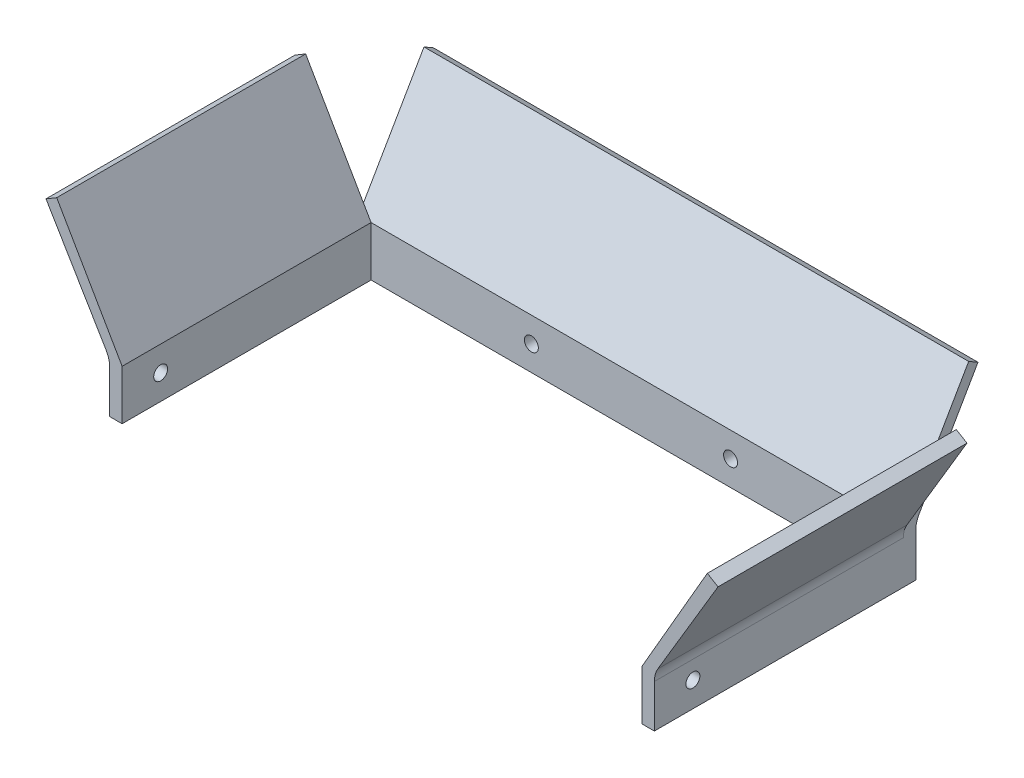
from build123d import *

# Parameters (mm, degrees)
SKETCH1_W           = 138.92560988
SKETCH1_H           = 12.7
SKETCH1_R           = 1.778
BOSS_EXTRUDE1_DEPTH = 3.175
SKETCH2_W           = 3.175
SKETCH2_H           = 12.7
BOSS_EXTRUDE2_DEPTH = 63.5
SKETCH3_R           = 1.778
CUT_EXTRUDE1_DEPTH  = 152.4
BOSS_EXTRUDE3_REACH = 156.619
BOSS_EXTRUDE4_DEPTH = 63.5
FILLET1_R           = 6.35


with BuildPart() as part:
    # Sketch1 → Boss-Extrude1 (new body)
    with BuildSketch(Plane.XY):
        with Locations((-69.46280494, -6.35)):
            Rectangle(SKETCH1_W, SKETCH1_H)
        with Locations((-94.86280494, -6.35)):
            Circle(SKETCH1_R, mode=Mode.SUBTRACT)
        with Locations((-44.06280494, -6.35)):
            Circle(SKETCH1_R, mode=Mode.SUBTRACT)
    extrude(amount=BOSS_EXTRUDE1_DEPTH)

    # Sketch2 → Boss-Extrude2 (add)
    with BuildSketch(Plane.XY.offset(3.175)):
        with Locations((-137.33810988, -6.35)):
            Rectangle(SKETCH2_W, SKETCH2_H)
        with Locations((-1.5875, -6.35)):
            Rectangle(SKETCH2_W, SKETCH2_H)
    extrude(amount=BOSS_EXTRUDE2_DEPTH)

    # Sketch3 → Cut-Extrude1 (cut)
    with BuildSketch(Plane(origin=(0, 0, 0), x_dir=(0, 0, -1), z_dir=(1, 0, 0))):
        with Locations(Location((-56.840236332, -6.35, 0), (0, 0, 90))):
            Circle(SKETCH3_R)
    extrude(amount=-CUT_EXTRUDE1_DEPTH, mode=Mode.SUBTRACT)

    # Boss-Extrude3: up to this face of the body (flat: up to its plane)
    boss_extrude3_end = Plane(part.part.faces().sort_by_distance((-138.92560988, -6.35, 33.058574097))[0])
    # Sketch5 → Boss-Extrude3 (add, up to the picked face)
    with BuildSketch(Plane(origin=(0, 0, 0), x_dir=(0, 0, -1), z_dir=(1, 0, 0)), mode=Mode.PRIVATE) as boss_extrude3_sk1:
        Polygon((-3.175, 0), (13.49375, 28.871121899), (15.875, 27.49630657), (0, 0), align=None)
    boss_extrude3_tool1 = split(extrude(boss_extrude3_sk1.sketch, amount=-BOSS_EXTRUDE3_REACH, mode=Mode.PRIVATE), bisect_by=boss_extrude3_end, keep=Keep.BOTH, mode=Mode.PRIVATE)
    add(boss_extrude3_tool1.solids().sort_by(Axis((0, 14.094651, -6.537144), (-1, 0, 0)))[0])

    # Sketch6 → Boss-Extrude4 (add)
    with BuildSketch(Plane.XY.offset(66.675)):
        Polygon((-3.175, 0), (13.513581363, 28.905470827), (16.241711333, 27.281299694), (0, 0), align=None)
        Polygon((-138.92560988, 0), (-155.167321213, 27.281299694), (-152.439191243, 28.905470827), (-135.75060988, 0), align=None)
    extrude(amount=-BOSS_EXTRUDE4_DEPTH)

    # Fillet1
    fillet1_edges = [part.edges().sort_by_distance(p)[0] for p in [
        (-69.46280494, 0, 0),
        (-138.92560988, 0, 34.925),
        (0, 0, 34.925),
    ]]
    fillet(fillet1_edges, radius=FILLET1_R)


solid = part.part
